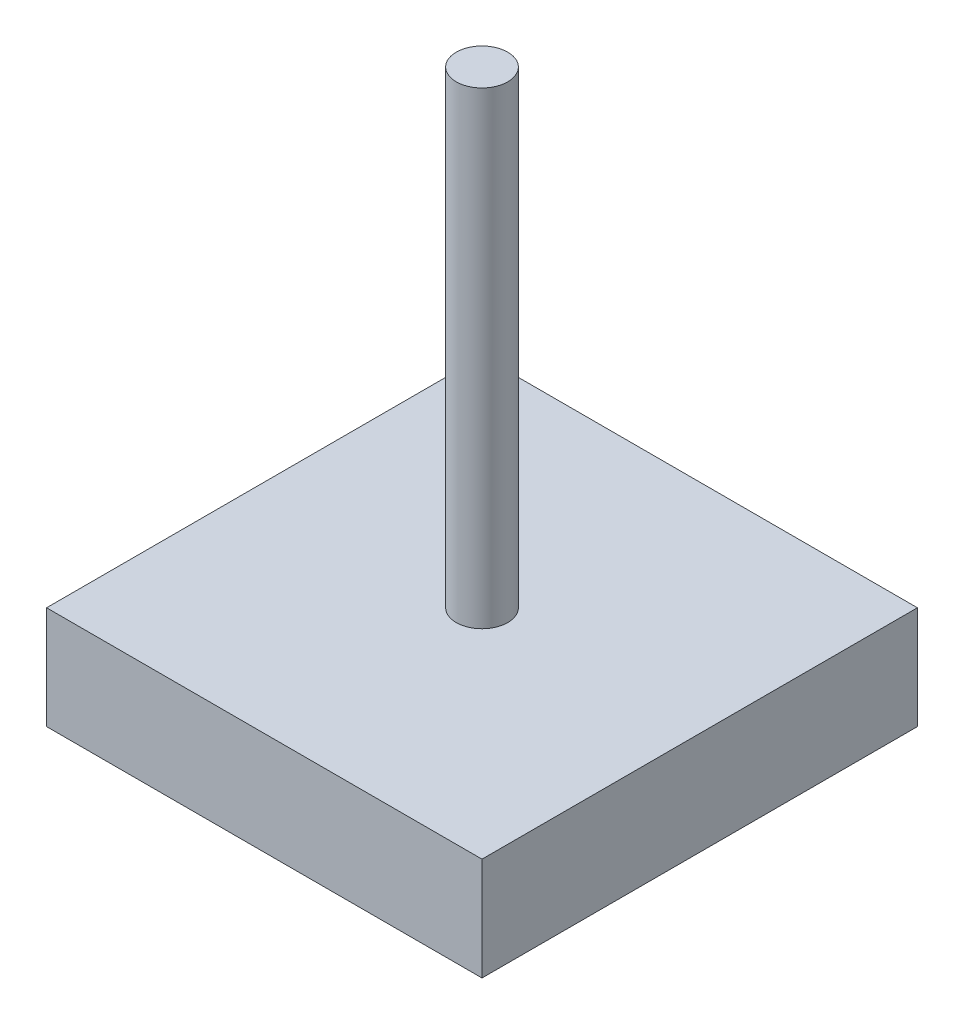
from build123d import *

# Parameters (mm, degrees)
SKETCH1_W           = 42.3
SKETCH1_H           = 42.3
BOSS_EXTRUDE1_DEPTH = 10
SKETCH2_R           = 2.5
BOSS_EXTRUDE2_DEPTH = 45.5


with BuildPart() as part:
    # Sketch1 → Boss-Extrude1 (new body)
    with BuildSketch(Plane(origin=(0, 0, 0), x_dir=(1, 0, 0), z_dir=(0, 1, 0))):
        Rectangle(SKETCH1_W, SKETCH1_H)
    extrude(amount=BOSS_EXTRUDE1_DEPTH)

    # Sketch2 → Boss-Extrude2 (add)
    with BuildSketch(Plane(origin=(0, 10, 0), x_dir=(1, 0, 0), z_dir=(0, 1, 0))):
        Circle(SKETCH2_R)
    extrude(amount=BOSS_EXTRUDE2_DEPTH)


solid = part.part
